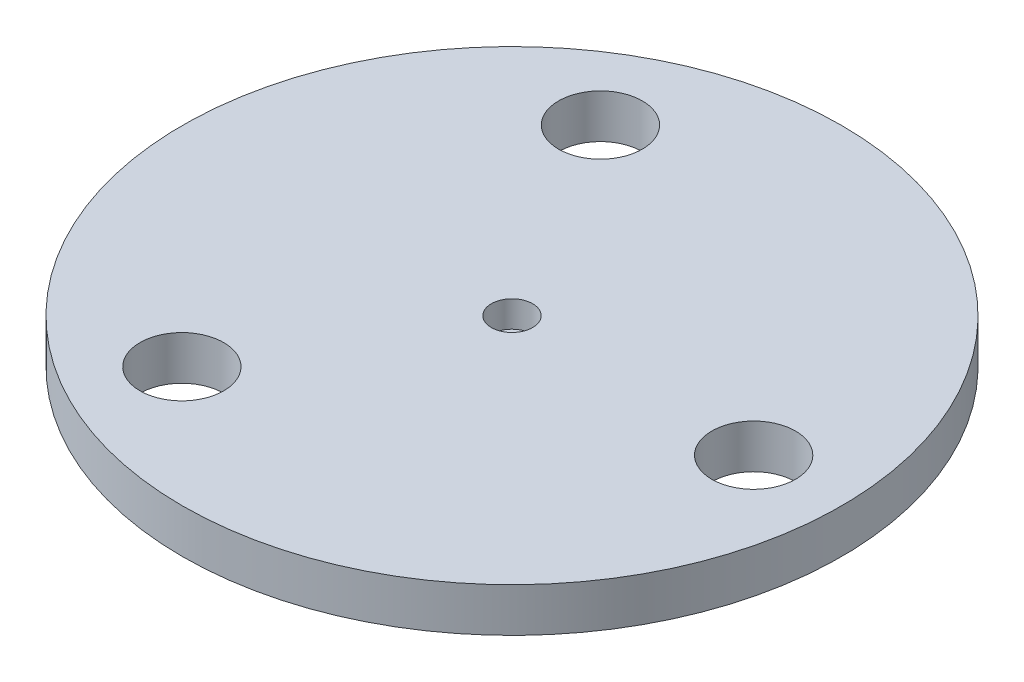
from build123d import *

# Parameters (mm, degrees)
SKETCH1_R           = 37.5
SKETCH1_R_2         = 2.35
BOSS_EXTRUDE1_DEPTH = 3
BOSS_EXTRUDE2_START = -2
SKETCH1_3_R         = 37.5
BOSS_EXTRUDE2_DEPTH = 2
SKETCH2_R           = 4.7625
CUT_EXTRUDE1_DEPTH  = 54.268189382
CIRPATTERN1_COUNT   = 3


with BuildPart() as part:
    # Sketch1 → Boss-Extrude1 (new body)
    with BuildSketch(Plane(origin=(0, 0, 0), x_dir=(1, 0, 0), z_dir=(0, 1, 0))):
        Circle(SKETCH1_R)
        Circle(SKETCH1_R_2, mode=Mode.SUBTRACT)
    extrude(amount=BOSS_EXTRUDE1_DEPTH)

    # Sketch1_3 → Boss-Extrude2 (add)
    with BuildSketch(Plane(origin=(0, 0, 0), x_dir=(1, 0, 0), z_dir=(0, 1, 0)).offset(BOSS_EXTRUDE2_START)):
        Circle(SKETCH1_3_R)
    extrude(amount=BOSS_EXTRUDE2_DEPTH)

    # Sketch2 → Cut-Extrude1 (cut, through all)
    with BuildSketch(Plane(origin=(0, 3, 0), x_dir=(1, 0, 0), z_dir=(0, 1, 0))):
        with Locations((27.5, 0)):
            Circle(SKETCH2_R)
    cut_extrude1 = extrude(amount=-CUT_EXTRUDE1_DEPTH, mode=Mode.SUBTRACT)

    # CirPattern1: Cut-Extrude1 ×3 about axis
    cirpattern1_axis = Axis((0, 3, 0), (0, 1, 0))
    for i in range(1, CIRPATTERN1_COUNT):
        add(cut_extrude1.rotate(cirpattern1_axis, i * 360 / CIRPATTERN1_COUNT), mode=Mode.SUBTRACT)


solid = part.part
